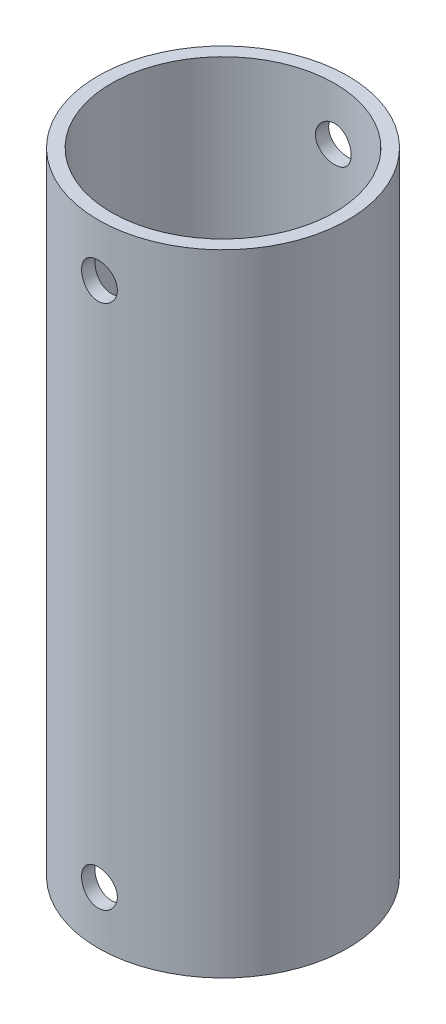
from build123d import *

# Parameters (mm, degrees)
BOSS_EXTRUDE1_DEPTH            = 76.2
BOSS_EXTRUDE1_DEPTH_BACK       = 76.2
SKETCH1_R                      = 30.1625
SKETCH1_R_2                    = 26.9875
CUT_EXTRUDE1_REACH             = 89.327
SKETCH2_R                      = 4.318
CUT_EXTRUDE1_DIRECTION_2_REACH = 89.327


with BuildPart() as part:
    # Sketch1 → Boss-Extrude1 (new, two sides: drawn at the far end of the back side and taken through both)
    with BuildSketch(Plane(origin=(0, 0, 0), x_dir=(1, 0, 0), z_dir=(0, 1, 0)).offset(-BOSS_EXTRUDE1_DEPTH_BACK)):
        Circle(SKETCH1_R)
        Circle(SKETCH1_R_2, mode=Mode.SUBTRACT)
    extrude(amount=BOSS_EXTRUDE1_DEPTH + BOSS_EXTRUDE1_DEPTH_BACK)

    # Sketch2 → Cut-Extrude1 (cut, up to next)
    with BuildSketch(Plane.XY, mode=Mode.PRIVATE) as cut_extrude1_sk1:
        with Locations((0, 63.5)):
            Circle(SKETCH2_R)
    cut_extrude1_tool1 = extrude(cut_extrude1_sk1.sketch, amount=-CUT_EXTRUDE1_REACH, mode=Mode.PRIVATE) & part.part
    # Sketch2 → Cut-Extrude1 (cut, up to next)
    with BuildSketch(Plane.XY, mode=Mode.PRIVATE) as cut_extrude1_sk2:
        with Locations((0, -63.5)):
            Circle(SKETCH2_R)
    cut_extrude1_tool2 = extrude(cut_extrude1_sk2.sketch, amount=-CUT_EXTRUDE1_REACH, mode=Mode.PRIVATE) & part.part
    add(cut_extrude1_tool1.solids().sort_by_distance((0, 63.5, 0))[0], mode=Mode.SUBTRACT)
    add(cut_extrude1_tool2.solids().sort_by_distance((0, -63.5, 0))[0], mode=Mode.SUBTRACT)

    # Sketch2 → Cut-Extrude1 direction 2 (cut, up to next)
    with BuildSketch(Plane.XY, mode=Mode.PRIVATE) as cut_extrude1_direction_2_sk1:
        with Locations((0, 63.5)):
            Circle(SKETCH2_R)
    cut_extrude1_direction_2_tool1 = extrude(cut_extrude1_direction_2_sk1.sketch, amount=CUT_EXTRUDE1_DIRECTION_2_REACH, mode=Mode.PRIVATE) & part.part
    # Sketch2 → Cut-Extrude1 direction 2 (cut, up to next)
    with BuildSketch(Plane.XY, mode=Mode.PRIVATE) as cut_extrude1_direction_2_sk2:
        with Locations((0, -63.5)):
            Circle(SKETCH2_R)
    cut_extrude1_direction_2_tool2 = extrude(cut_extrude1_direction_2_sk2.sketch, amount=CUT_EXTRUDE1_DIRECTION_2_REACH, mode=Mode.PRIVATE) & part.part
    add(cut_extrude1_direction_2_tool1.solids().sort_by_distance((0, 63.5, 0))[0], mode=Mode.SUBTRACT)
    add(cut_extrude1_direction_2_tool2.solids().sort_by_distance((0, -63.5, 0))[0], mode=Mode.SUBTRACT)


solid = part.part
